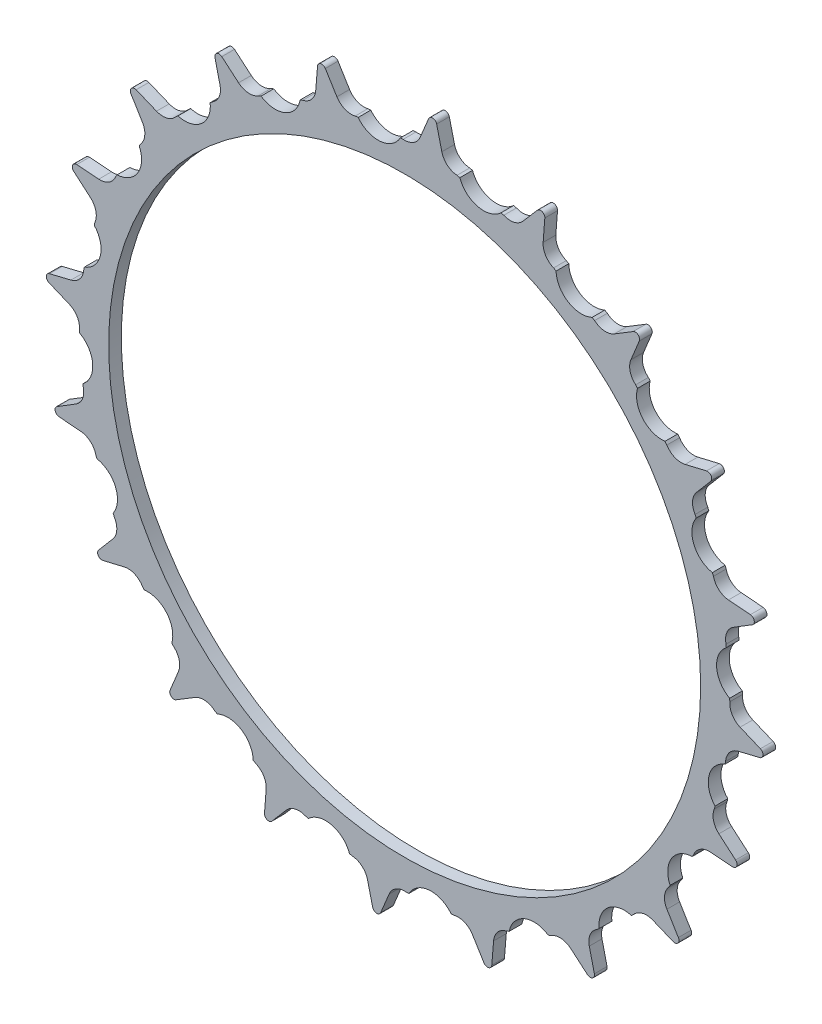
from build123d import *

# Parameters (mm, degrees)
BOSS_EXTRUDE1_DEPTH                 = 3
SKETCH2_R                           = 12.5
BOSS_EXTRUDE2_DEPTH                 = 40
FILLET1_R                           = 30
SKETCH3_R                           = 5
CUT_EXTRUDE1_DEPTH                  = 44
F_1_0MM_DOWEL_HOLE1_D               = 2.8
F_1_0MM_DOWEL_HOLE1_DEPTH           = 33.158795133
F_1_0MM_DOWEL_HOLE1_TIP             = 0.841204867
F_1_0MM_DOWEL_HOLE1_ON_FACE_2_D     = 2.8
F_1_0MM_DOWEL_HOLE1_ON_FACE_2_DEPTH = 33.158795133
F_1_0MM_DOWEL_HOLE1_ON_FACE_2_TIP   = 0.841204867
CUT_EXTRUDE2_DEPTH                  = 10
CIRPATTERN1_COUNT                   = 20
CUT_EXTRUDE3_DEPTH                  = 44.0000001
SKETCH8_W                           = 174.571261172
SKETCH8_H                           = 39.716241256
CUT_EXTRUDE4_DEPTH                  = 85.741056034
CUT_EXTRUDE4_DEPTH_BACK             = 85.741056034
SKETCH9_R                           = 70
CUT_EXTRUDE5_DEPTH                  = 4


with BuildPart() as part:
    # Sketch1 → Boss-Extrude1 (new body)
    with BuildSketch(Plane.XY):
        with BuildLine():
            ThreePointArc((3.662609618, 79.321514688), (0, 76.88125), (-3.662609618, 79.321514688))
            Line((-3.662609618, 79.321514688), (-5.667701775, 84.126186191))
            ThreePointArc((-5.667701775, 84.126186191), (-6.669023137, 84.737973367), (-7.562311971, 83.977077135))
            Line((-7.562311971, 83.977077135), (-8.791101901, 78.917893592))
            ThreePointArc((-8.791101901, 78.917893592), (-12.026877215, 75.934714235), (-16.026135532, 77.77197684))
            Line((-16.026135532, 77.77197684), (-18.758157894, 82.203829344))
            ThreePointArc((-18.758157894, 82.203829344), (-19.842855928, 82.651443234), (-20.606116499, 81.760173735))
            Line((-20.606116499, 81.760173735), (-21.028347314, 76.571052042))
            ThreePointArc((-21.028347314, 76.571052042), (-23.757612799, 73.118413793), (-27.995044802, 74.307434811))
            Line((-27.995044802, 74.307434811), (-31.386725911, 78.2573414))
            ThreePointArc((-31.386725911, 78.2573414), (-32.528091751, 78.529760263), (-33.142530051, 77.530063512))
            Line((-33.142530051, 77.530063512), (-32.747805028, 72.338777067))
            ThreePointArc((-32.747805028, 72.338777067), (-34.903357108, 68.501695338), (-39.274623159, 69.013197125))
            Line((-39.274623159, 69.013197125), (-43.242448569, 72.38389799))
            ThreePointArc((-43.242448569, 72.38389799), (-44.412378001, 72.47441397), (-44.862864519, 71.390905818))
            Line((-44.862864519, 71.390905818), (-43.660903098, 66.325281321))
            ThreePointArc((-43.660903098, 66.325281321), (-45.189664928, 62.198237799), (-49.587129948, 62.019625484))
            Line((-49.587129948, 62.019625484), (-54.03339863, 64.728122783))
            ThreePointArc((-54.03339863, 64.728122783), (-55.203084108, 64.634507076), (-55.478526372, 63.49386709))
            Line((-55.478526372, 63.49386709), (-53.498924832, 58.678637028))
            ThreePointArc((-53.498924832, 58.678637028), (-54.363253221, 54.363253221), (-58.678637028, 53.498924832))
            Line((-58.678637028, 53.498924832), (-63.49386709, 55.478526372))
            ThreePointArc((-63.49386709, 55.478526372), (-64.634507076, 55.203084108), (-64.728122783, 54.03339863))
            Line((-64.728122783, 54.03339863), (-62.019625484, 49.587129948))
            ThreePointArc((-62.019625484, 49.587129948), (-62.198237799, 45.189664928), (-66.325281321, 43.660903098))
            Line((-66.325281321, 43.660903098), (-71.390905818, 44.862864519))
            ThreePointArc((-71.390905818, 44.862864519), (-72.47441397, 44.412378001), (-72.38389799, 43.242448569))
            Line((-72.38389799, 43.242448569), (-69.013197125, 39.274623159))
            ThreePointArc((-69.013197125, 39.274623159), (-68.501695338, 34.903357108), (-72.338777067, 32.747805028))
            Line((-72.338777067, 32.747805028), (-77.530063512, 33.142530051))
            ThreePointArc((-77.530063512, 33.142530051), (-78.529760263, 32.528091751), (-78.2573414, 31.386725911))
            Line((-78.2573414, 31.386725911), (-74.307434811, 27.995044802))
            ThreePointArc((-74.307434811, 27.995044802), (-73.118413793, 23.757612799), (-76.571052042, 21.028347314))
            Line((-76.571052042, 21.028347314), (-81.760173735, 20.606116499))
            ThreePointArc((-81.760173735, 20.606116499), (-82.651443234, 19.842855928), (-82.203829344, 18.758157894))
            Line((-82.203829344, 18.758157894), (-77.77197684, 16.026135532))
            ThreePointArc((-77.77197684, 16.026135532), (-75.934714235, 12.026877215), (-78.917893592, 8.791101901))
            Line((-78.917893592, 8.791101901), (-83.977077135, 7.562311971))
            ThreePointArc((-83.977077135, 7.562311971), (-84.737973367, 6.669023137), (-84.126186191, 5.667701775))
            Line((-84.126186191, 5.667701775), (-79.321514688, 3.662609618))
            ThreePointArc((-79.321514688, 3.662609618), (-76.88125, 0), (-79.321514688, -3.662609618))
            Line((-79.321514688, -3.662609618), (-84.126186191, -5.667701775))
            ThreePointArc((-84.126186191, -5.667701775), (-84.737973367, -6.669023137), (-83.977077135, -7.562311971))
            Line((-83.977077135, -7.562311971), (-78.917893592, -8.791101901))
            ThreePointArc((-78.917893592, -8.791101901), (-75.934714235, -12.026877215), (-77.77197684, -16.026135532))
            Line((-77.77197684, -16.026135532), (-82.203829344, -18.758157894))
            ThreePointArc((-82.203829344, -18.758157894), (-82.651443234, -19.842855928), (-81.760173735, -20.606116499))
            Line((-81.760173735, -20.606116499), (-76.571052042, -21.028347314))
            ThreePointArc((-76.571052042, -21.028347314), (-73.118413793, -23.757612799), (-74.307434811, -27.995044802))
            Line((-74.307434811, -27.995044802), (-78.2573414, -31.386725911))
            ThreePointArc((-78.2573414, -31.386725911), (-78.529760263, -32.528091751), (-77.530063512, -33.142530051))
            Line((-77.530063512, -33.142530051), (-72.338777067, -32.747805028))
            ThreePointArc((-72.338777067, -32.747805028), (-68.501695338, -34.903357108), (-69.013197125, -39.274623159))
            Line((-69.013197125, -39.274623159), (-72.38389799, -43.242448569))
            ThreePointArc((-72.38389799, -43.242448569), (-72.47441397, -44.412378001), (-71.390905818, -44.862864519))
            Line((-71.390905818, -44.862864519), (-66.325281321, -43.660903098))
            ThreePointArc((-66.325281321, -43.660903098), (-62.198237799, -45.189664928), (-62.019625484, -49.587129948))
            Line((-62.019625484, -49.587129948), (-64.728122783, -54.03339863))
            ThreePointArc((-64.728122783, -54.03339863), (-64.634507076, -55.203084108), (-63.49386709, -55.478526372))
            Line((-63.49386709, -55.478526372), (-58.678637028, -53.498924832))
            ThreePointArc((-58.678637028, -53.498924832), (-54.363253221, -54.363253221), (-53.498924832, -58.678637028))
            Line((-53.498924832, -58.678637028), (-55.478526372, -63.49386709))
            ThreePointArc((-55.478526372, -63.49386709), (-55.203084108, -64.634507076), (-54.03339863, -64.728122783))
            Line((-54.03339863, -64.728122783), (-49.587129948, -62.019625484))
            ThreePointArc((-49.587129948, -62.019625484), (-45.189664928, -62.198237799), (-43.660903098, -66.325281321))
            Line((-43.660903098, -66.325281321), (-44.862864519, -71.390905818))
            ThreePointArc((-44.862864519, -71.390905818), (-44.412378001, -72.47441397), (-43.242448569, -72.38389799))
            Line((-43.242448569, -72.38389799), (-39.274623159, -69.013197125))
            ThreePointArc((-39.274623159, -69.013197125), (-34.903357108, -68.501695338), (-32.747805028, -72.338777067))
            Line((-32.747805028, -72.338777067), (-33.142530051, -77.530063512))
            ThreePointArc((-33.142530051, -77.530063512), (-32.528091751, -78.529760263), (-31.386725911, -78.2573414))
            Line((-31.386725911, -78.2573414), (-27.995044802, -74.307434811))
            ThreePointArc((-27.995044802, -74.307434811), (-23.757612799, -73.118413793), (-21.028347314, -76.571052042))
            Line((-21.028347314, -76.571052042), (-20.606116499, -81.760173735))
            ThreePointArc((-20.606116499, -81.760173735), (-19.842855928, -82.651443234), (-18.758157894, -82.203829344))
            Line((-18.758157894, -82.203829344), (-16.026135532, -77.77197684))
            ThreePointArc((-16.026135532, -77.77197684), (-12.026877215, -75.934714235), (-8.791101901, -78.917893592))
            Line((-8.791101901, -78.917893592), (-7.562311971, -83.977077135))
            ThreePointArc((-7.562311971, -83.977077135), (-6.669023137, -84.737973367), (-5.667701775, -84.126186191))
            Line((-5.667701775, -84.126186191), (-3.662609618, -79.321514688))
            ThreePointArc((-3.662609618, -79.321514688), (0, -76.88125), (3.662609618, -79.321514688))
            Line((3.662609618, -79.321514688), (5.667701775, -84.126186191))
            ThreePointArc((5.667701775, -84.126186191), (6.669023137, -84.737973367), (7.562311971, -83.977077135))
            Line((7.562311971, -83.977077135), (8.791101901, -78.917893592))
            ThreePointArc((8.791101901, -78.917893592), (12.026877215, -75.934714235), (16.026135532, -77.77197684))
            Line((16.026135532, -77.77197684), (18.758157894, -82.203829344))
            ThreePointArc((18.758157894, -82.203829344), (19.842855928, -82.651443234), (20.606116499, -81.760173735))
            Line((20.606116499, -81.760173735), (21.028347314, -76.571052042))
            ThreePointArc((21.028347314, -76.571052042), (23.757612799, -73.118413793), (27.995044802, -74.307434811))
            Line((27.995044802, -74.307434811), (31.386725911, -78.2573414))
            ThreePointArc((31.386725911, -78.2573414), (32.528091751, -78.529760263), (33.142530051, -77.530063512))
            Line((33.142530051, -77.530063512), (32.747805028, -72.338777067))
            ThreePointArc((32.747805028, -72.338777067), (34.903357108, -68.501695338), (39.274623159, -69.013197125))
            Line((39.274623159, -69.013197125), (43.242448569, -72.38389799))
            ThreePointArc((43.242448569, -72.38389799), (44.412378001, -72.47441397), (44.862864519, -71.390905818))
            Line((44.862864519, -71.390905818), (43.660903098, -66.325281321))
            ThreePointArc((43.660903098, -66.325281321), (45.189664928, -62.198237799), (49.587129948, -62.019625484))
            Line((49.587129948, -62.019625484), (54.03339863, -64.728122783))
            ThreePointArc((54.03339863, -64.728122783), (55.203084108, -64.634507076), (55.478526372, -63.49386709))
            Line((55.478526372, -63.49386709), (53.498924832, -58.678637028))
            ThreePointArc((53.498924832, -58.678637028), (54.363253221, -54.363253221), (58.678637028, -53.498924832))
            Line((58.678637028, -53.498924832), (63.49386709, -55.478526372))
            ThreePointArc((63.49386709, -55.478526372), (64.634507076, -55.203084108), (64.728122783, -54.03339863))
            Line((64.728122783, -54.03339863), (62.019625484, -49.587129948))
            ThreePointArc((62.019625484, -49.587129948), (62.198237799, -45.189664928), (66.325281321, -43.660903098))
            Line((66.325281321, -43.660903098), (71.390905818, -44.862864519))
            ThreePointArc((71.390905818, -44.862864519), (72.47441397, -44.412378001), (72.38389799, -43.242448569))
            Line((72.38389799, -43.242448569), (69.013197125, -39.274623159))
            ThreePointArc((69.013197125, -39.274623159), (68.501695338, -34.903357108), (72.338777067, -32.747805028))
            Line((72.338777067, -32.747805028), (77.530063512, -33.142530051))
            ThreePointArc((77.530063512, -33.142530051), (78.529760263, -32.528091751), (78.2573414, -31.386725911))
            Line((78.2573414, -31.386725911), (74.307434811, -27.995044802))
            ThreePointArc((74.307434811, -27.995044802), (73.118413793, -23.757612799), (76.571052042, -21.028347314))
            Line((76.571052042, -21.028347314), (81.760173735, -20.606116499))
            ThreePointArc((81.760173735, -20.606116499), (82.651443234, -19.842855928), (82.203829344, -18.758157894))
            Line((82.203829344, -18.758157894), (77.77197684, -16.026135532))
            ThreePointArc((77.77197684, -16.026135532), (75.934714235, -12.026877215), (78.917893592, -8.791101901))
            Line((78.917893592, -8.791101901), (83.977077135, -7.562311971))
            ThreePointArc((83.977077135, -7.562311971), (84.737973367, -6.669023137), (84.126186191, -5.667701775))
            Line((84.126186191, -5.667701775), (79.321514688, -3.662609618))
            ThreePointArc((79.321514688, -3.662609618), (76.88125, 0), (79.321514688, 3.662609618))
            Line((79.321514688, 3.662609618), (84.126186191, 5.667701775))
            ThreePointArc((84.126186191, 5.667701775), (84.737973367, 6.669023137), (83.977077135, 7.562311971))
            Line((83.977077135, 7.562311971), (78.917893592, 8.791101901))
            ThreePointArc((78.917893592, 8.791101901), (75.934714235, 12.026877215), (77.77197684, 16.026135532))
            Line((77.77197684, 16.026135532), (82.203829344, 18.758157894))
            ThreePointArc((82.203829344, 18.758157894), (82.651443234, 19.842855928), (81.760173735, 20.606116499))
            Line((81.760173735, 20.606116499), (76.571052042, 21.028347314))
            ThreePointArc((76.571052042, 21.028347314), (73.118413793, 23.757612799), (74.307434811, 27.995044802))
            Line((74.307434811, 27.995044802), (78.2573414, 31.386725911))
            ThreePointArc((78.2573414, 31.386725911), (78.529760263, 32.528091751), (77.530063512, 33.142530051))
            Line((77.530063512, 33.142530051), (72.338777067, 32.747805028))
            ThreePointArc((72.338777067, 32.747805028), (68.501695338, 34.903357108), (69.013197125, 39.274623159))
            Line((69.013197125, 39.274623159), (72.38389799, 43.242448569))
            ThreePointArc((72.38389799, 43.242448569), (72.47441397, 44.412378001), (71.390905818, 44.862864519))
            Line((71.390905818, 44.862864519), (66.325281321, 43.660903098))
            ThreePointArc((66.325281321, 43.660903098), (62.198237799, 45.189664928), (62.019625484, 49.587129948))
            Line((62.019625484, 49.587129948), (64.728122783, 54.03339863))
            ThreePointArc((64.728122783, 54.03339863), (64.634507076, 55.203084108), (63.49386709, 55.478526372))
            Line((63.49386709, 55.478526372), (58.678637028, 53.498924832))
            ThreePointArc((58.678637028, 53.498924832), (54.363253221, 54.363253221), (53.498924832, 58.678637028))
            Line((53.498924832, 58.678637028), (55.478526372, 63.49386709))
            ThreePointArc((55.478526372, 63.49386709), (55.203084108, 64.634507076), (54.03339863, 64.728122783))
            Line((54.03339863, 64.728122783), (49.587129948, 62.019625484))
            ThreePointArc((49.587129948, 62.019625484), (45.189664928, 62.198237799), (43.660903098, 66.325281321))
            Line((43.660903098, 66.325281321), (44.862864519, 71.390905818))
            ThreePointArc((44.862864519, 71.390905818), (44.412378001, 72.47441397), (43.242448569, 72.38389799))
            Line((43.242448569, 72.38389799), (39.274623159, 69.013197125))
            ThreePointArc((39.274623159, 69.013197125), (34.903357108, 68.501695338), (32.747805028, 72.338777067))
            Line((32.747805028, 72.338777067), (33.142530051, 77.530063512))
            ThreePointArc((33.142530051, 77.530063512), (32.528091751, 78.529760263), (31.386725911, 78.2573414))
            Line((31.386725911, 78.2573414), (27.995044802, 74.307434811))
            ThreePointArc((27.995044802, 74.307434811), (23.757612799, 73.118413793), (21.028347314, 76.571052042))
            Line((21.028347314, 76.571052042), (20.606116499, 81.760173735))
            ThreePointArc((20.606116499, 81.760173735), (19.842855928, 82.651443234), (18.758157894, 82.203829344))
            Line((18.758157894, 82.203829344), (16.026135532, 77.77197684))
            ThreePointArc((16.026135532, 77.77197684), (12.026877215, 75.934714235), (8.791101901, 78.917893592))
            Line((8.791101901, 78.917893592), (7.562311971, 83.977077135))
            ThreePointArc((7.562311971, 83.977077135), (6.669023137, 84.737973367), (5.667701775, 84.126186191))
            Line((5.667701775, 84.126186191), (3.662609618, 79.321514688))
        make_face()
    extrude(amount=BOSS_EXTRUDE1_DEPTH)

    # Sketch2 → Boss-Extrude2 (add)
    with BuildSketch(Plane.XY.offset(3)):
        Circle(SKETCH2_R)
    extrude(amount=BOSS_EXTRUDE2_DEPTH)

    # Fillet1
    fillet1_edges = [part.edges().sort_by_distance(p)[0] for p in [
        (-12.5, 0, 3),
    ]]
    fillet(fillet1_edges, radius=FILLET1_R)

    # Sketch3 → Cut-Extrude1 (cut, through all)
    with BuildSketch(Plane.XY.offset(43)):
        Circle(SKETCH3_R)
    extrude(amount=-CUT_EXTRUDE1_DEPTH, mode=Mode.SUBTRACT)

    # Ø1.0mm Dowel Hole1
    with Locations(Plane(origin=(-6.81763654, -10.477109907, 42.020116055), x_dir=(-0.838168793, 0.545410923, 0), z_dir=(-0.545410923, -0.838168793, 0))):
        with Locations((0, 0)):
            Hole(F_1_0MM_DOWEL_HOLE1_D / 2, depth=F_1_0MM_DOWEL_HOLE1_DEPTH)
            with Locations((0, 0, -(F_1_0MM_DOWEL_HOLE1_DEPTH + F_1_0MM_DOWEL_HOLE1_TIP / 2))):  # 118° drill point
                Cone(0, F_1_0MM_DOWEL_HOLE1_D / 2, F_1_0MM_DOWEL_HOLE1_TIP, mode=Mode.SUBTRACT)

    # Ø1.0mm Dowel Hole1 on face 2
    with Locations(Plane(origin=(-11.068439798, 5.808583342, 41.658255729), x_dir=(-0.464687004, -0.885475007, 0), z_dir=(-0.885475007, 0.464687004, 0))):
        with Locations((0, 0)):
            Hole(F_1_0MM_DOWEL_HOLE1_ON_FACE_2_D / 2, depth=F_1_0MM_DOWEL_HOLE1_ON_FACE_2_DEPTH)
            with Locations((0, 0, -(F_1_0MM_DOWEL_HOLE1_ON_FACE_2_DEPTH + F_1_0MM_DOWEL_HOLE1_ON_FACE_2_TIP / 2))):  # 118° drill point
                Cone(0, F_1_0MM_DOWEL_HOLE1_ON_FACE_2_D / 2, F_1_0MM_DOWEL_HOLE1_ON_FACE_2_TIP, mode=Mode.SUBTRACT)

    # Sketch5 → Cut-Extrude2 (cut)
    with BuildSketch(Plane(origin=(0, 0, 0), x_dir=(-1, 0, 0), z_dir=(0, 0, -1))):
        with BuildLine():
            Line((-0.961651803, 76.999519203), (1.032182864, 76.842601011))
            ThreePointArc((1.032182864, 76.842601011), (5.80623434, 73.775202273), (11.001356201, 76.058010054))
            Line((11.001356201, 76.058010054), (12.995190869, 75.901091862))
            Line((12.995190869, 75.901091862), (13.647444473, 84.188759697))
            Line((13.647444473, 84.188759697), (-0.309398199, 85.287187037))
            Line((-0.309398199, 85.287187037), (-0.961651803, 76.999519203))
        make_face()
    cut_extrude2 = extrude(amount=-CUT_EXTRUDE2_DEPTH, mode=Mode.SUBTRACT)

    # CirPattern1: Cut-Extrude2 ×20 about axis
    cirpattern1_axis = Axis((0, 0, 0), (0, 0, 1))
    for i in range(1, CIRPATTERN1_COUNT):
        add(cut_extrude2.rotate(cirpattern1_axis, i * 360 / CIRPATTERN1_COUNT), mode=Mode.SUBTRACT)

    # Sketch7 → Cut-Extrude3 (cut, through all)
    with BuildSketch(Plane(origin=(0, 0, 0), x_dir=(-1, 0, 0), z_dir=(0, 0, -1))):
        Polygon((12.5, -7.216878365), (12.5, 7.216878365), (0, 14.43375673), (-12.5, 7.216878365), (-12.5, -7.216878365), (0, -14.43375673), align=None)
    extrude(amount=-CUT_EXTRUDE3_DEPTH, mode=Mode.SUBTRACT)

    # Sketch8 → Cut-Extrude4 (cut, two sides)
    with BuildSketch(Plane(origin=(0, 0, 0), x_dir=(1, 0, 0), z_dir=(0, 1, 0))) as cut_extrude4_sk:
        with Locations((3.308553451, -22.858120628)):
            Rectangle(SKETCH8_W, SKETCH8_H)
    extrude(amount=CUT_EXTRUDE4_DEPTH, mode=Mode.SUBTRACT)
    extrude(cut_extrude4_sk.sketch, amount=-CUT_EXTRUDE4_DEPTH_BACK, mode=Mode.SUBTRACT)

    # Sketch9 → Cut-Extrude5 (cut, through all)
    with BuildSketch(Plane.XY.offset(3)):
        Circle(SKETCH9_R)
    extrude(amount=-CUT_EXTRUDE5_DEPTH, mode=Mode.SUBTRACT)


solid = part.part
